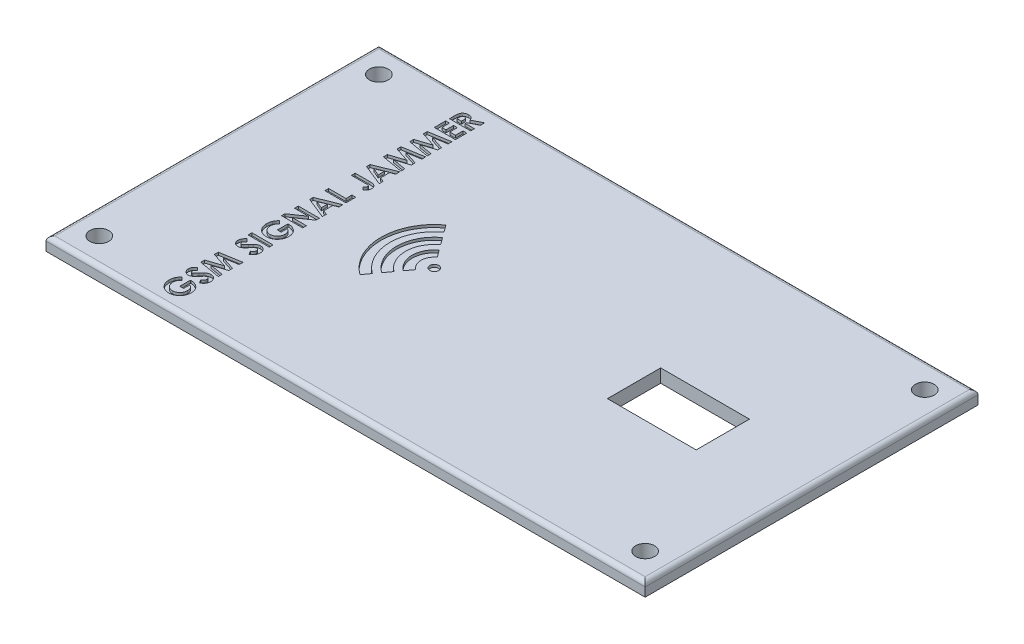
from build123d import *

# Parameters (mm, degrees)
SKETCH1_W                 = 135
SKETCH1_H                 = 75
BOSS_EXTRUDE1_DEPTH       = 3
SKETCH2_W                 = 20
SKETCH2_H                 = 12
CUT_EXTRUDE1_DEPTH        = 3
SKETCH7_W                 = 4.7625
SKETCH7_H                 = 0.854807692
CUT_EXTRUDE2_DEPTH        = 0.6
SKETCH8_R                 = 1
CUT_EXTRUDE3_DEPTH        = 0.6
F_4_0MM_DOWEL_HOLE1_D     = 4.25
F_4_0MM_DOWEL_HOLE1_DEPTH = 7.523171185
F_4_0MM_DOWEL_HOLE1_TIP   = 1.276828815
FILLET1_R                 = 1


with BuildPart() as part:
    # Sketch1 → Boss-Extrude1 (new body)
    with BuildSketch(Plane(origin=(0, 0, 0), x_dir=(1, 0, 0), z_dir=(0, 1, 0))):
        with Locations((67.5, 37.5)):
            Rectangle(SKETCH1_W, SKETCH1_H)
    extrude(amount=BOSS_EXTRUDE1_DEPTH)

    # Sketch2 → Cut-Extrude1 (cut)
    with BuildSketch(Plane(origin=(0, 3, 0), x_dir=(1, 0, 0), z_dir=(0, 1, 0))):
        with Locations((105, 37.5)):
            Rectangle(SKETCH2_W, SKETCH2_H)
    extrude(amount=-CUT_EXTRUDE1_DEPTH, mode=Mode.SUBTRACT)

    # Sketch7 → Cut-Extrude2 (cut)
    with BuildSketch(Plane(origin=(0, 3, 0), x_dir=(1, 0, 0), z_dir=(0, 1, 0))):
        with BuildLine():
            Line((23.338160871, 7.306017127), (23.957324032, 6.6591872))
            add(Edge.make_bspline(
                [(23.957324032, 6.6591872), (23.906052018, 6.607976545), (23.805447863, 6.507492788), (23.674504641, 6.343164172), (23.563177017, 6.172969598), (23.471635656, 5.996348887), (23.400628218, 5.813056007), (23.349834326, 5.623452671), (23.319707608, 5.427230421), (23.31548997, 5.294396716), (23.313356183, 5.22719351)],
                knots=[0, 0, 0, 0, 0.000217258, 0.000426297, 0.000628991, 0.000826548, 0.001021965, 0.001217513, 0.001414369, 0.001615942, 0.001615942, 0.001615942, 0.001615942], degree=3))
            add(Edge.make_bspline(
                [(23.313356183, 5.22719351), (23.314851318, 5.168930384), (23.317787146, 5.05452563), (23.340081624, 4.886418864), (23.377323542, 4.725782545), (23.428916015, 4.571857793), (23.496054083, 4.42558425), (23.577701753, 4.286114836), (23.674482851, 4.154306123), (23.784565735, 4.031202576), (23.904745004, 3.919097413), (24.033411846, 3.821291896), (24.168264114, 3.737584934), (24.310056355, 3.669746178), (24.457744893, 3.616832651), (24.611929925, 3.579833942), (24.772280944, 3.556119852), (24.88169152, 3.553334094), (24.937109188, 3.551923077)],
                knots=[0, 0, 0, 0, 0.000174754, 0.000343144, 0.000507682, 0.000668786, 0.000829303, 0.000989654, 0.001152803, 0.001319023, 0.001484411, 0.001645073, 0.001803137, 0.00195974, 0.002115749, 0.002272862, 0.002434766, 0.002600942, 0.002600942, 0.002600942, 0.002600942], degree=3))
            add(Edge.make_bspline(
                [(24.937109188, 3.551923077), (24.994443404, 3.553242806), (25.107399658, 3.555842852), (25.27316782, 3.580819237), (25.432648723, 3.619299664), (25.584659126, 3.675624723), (25.731281088, 3.744943908), (25.86967543, 3.83285169), (26.001951618, 3.935362339), (26.125821864, 4.052286207), (26.239955534, 4.179488914), (26.338572241, 4.317181415), (26.4231283, 4.461616339), (26.4922104, 4.613704993), (26.544395753, 4.773251712), (26.582972772, 4.93948426), (26.60620628, 5.113324289), (26.609035652, 5.231893196), (26.610471568, 5.292067308)],
                knots=[0, 0, 0, 0, 0.000171894, 0.000338655, 0.000501783, 0.00066325, 0.000824119, 0.000987439, 0.001154033, 0.001325466, 0.001497786, 0.001665917, 0.001832653, 0.001999171, 0.002166006, 0.002335407, 0.002510543, 0.002691015, 0.002691015, 0.002691015, 0.002691015], degree=3))
            add(Edge.make_bspline(
                [(26.610471568, 5.292067308), (26.610118385, 5.331210592), (26.609425008, 5.408057568), (26.59816955, 5.520778986), (26.582078564, 5.62873903), (26.560776009, 5.732355799), (26.530629072, 5.830583043), (26.495375941, 5.924780783), (26.453770217, 6.014397106), (26.404376426, 6.09894612), (26.349012023, 6.179686159), (26.285663373, 6.255861482), (26.215758755, 6.328808294), (26.138444185, 6.397674219), (26.053028378, 6.461293683), (25.961080966, 6.521704891), (25.861689424, 6.578216145), (25.791504153, 6.611607155), (25.755663876, 6.628658353)],
                knots=[0, 0, 0, 0, 0.00011738, 0.000230443, 0.000339461, 0.000444807, 0.000547426, 0.000647362, 0.000746379, 0.000843413, 0.000940799, 0.001039742, 0.001140277, 0.001243669, 0.001349948, 0.001459495, 0.001573568, 0.001692607, 0.001692607, 0.001692607, 0.001692607], degree=3))
            Line((25.755663876, 6.628658353), (25.755663876, 5.261538462))
            Line((25.755663876, 5.261538462), (24.900856183, 5.261538462))
            Line((24.900856183, 5.261538462), (24.900856183, 7.636110276))
            Line((24.900856183, 7.636110276), (25.104063816, 7.642788462))
            add(Edge.make_bspline(
                [(25.104063816, 7.642788462), (25.156252691, 7.641930364), (25.260537308, 7.640215702), (25.415799336, 7.624545482), (25.569002134, 7.598588), (25.719991837, 7.563101645), (25.869509069, 7.518628237), (26.01612221, 7.46191083), (26.160825039, 7.395494684), (26.303004592, 7.321081645), (26.439424151, 7.237457056), (26.568615708, 7.147443582), (26.690260901, 7.052230521), (26.802845911, 6.950239119), (26.906246602, 6.841691569), (27.001765919, 6.727898728), (27.090237668, 6.608821027), (27.168230316, 6.482349265), (27.237766338, 6.350609057), (27.299587689, 6.213607668), (27.350656037, 6.070543125), (27.392864253, 5.922056781), (27.425331935, 5.768078632), (27.44762025, 5.608671435), (27.462758501, 5.443729396), (27.464428849, 5.331853392), (27.46527926, 5.274894832)],
                knots=[0, 0, 0, 0, 0.000156533, 0.000312787, 0.000467589, 0.000622403, 0.000777839, 0.000935173, 0.001093558, 0.001255296, 0.001416298, 0.001573237, 0.001727451, 0.001879416, 0.002028541, 0.002176833, 0.002324904, 0.002473156, 0.002622097, 0.002771563, 0.002923658, 0.003077374, 0.00323436, 0.00339532, 0.003560035, 0.003730872, 0.003730872, 0.003730872, 0.003730872], degree=3))
            add(Edge.make_bspline(
                [(27.46527926, 5.274894832), (27.464429267, 5.214126151), (27.462744328, 5.0936645), (27.447305867, 4.915505531), (27.421036225, 4.742734744), (27.387428249, 4.57443496), (27.341155728, 4.411829583), (27.286016798, 4.25352959), (27.219709968, 4.100820035), (27.144785923, 3.952945679), (27.059764356, 3.811854234), (26.966194498, 3.677846513), (26.863458926, 3.55165804), (26.75328156, 3.431995149), (26.632953107, 3.321653993), (26.506374372, 3.216522214), (26.368902553, 3.12169422), (26.224995749, 3.033088366), (26.074709712, 2.954382683), (25.920840856, 2.885507557), (25.764504008, 2.827046132), (25.604633786, 2.780215561), (25.442172146, 2.743117084), (25.27653831, 2.716036747), (25.108164136, 2.700886712), (24.995015237, 2.698378075), (24.938063215, 2.697115385)],
                knots=[0, 0, 0, 0, 0.000182281, 0.000361336, 0.000535926, 0.000706376, 0.00087582, 0.001042677, 0.00120891, 0.001374883, 0.001539643, 0.001702678, 0.001864787, 0.002027478, 0.00219017, 0.002354224, 0.002520698, 0.002690699, 0.002860968, 0.003029226, 0.003196159, 0.003361283, 0.003528611, 0.003695805, 0.003864406, 0.004035273, 0.004035273, 0.004035273, 0.004035273], degree=3))
            add(Edge.make_bspline(
                [(24.938063215, 2.697115385), (24.860366388, 2.69879944), (24.706938191, 2.702124951), (24.480959382, 2.733041791), (24.262557879, 2.780899005), (24.052338117, 2.850605168), (23.849452604, 2.938481046), (23.654079862, 3.045715015), (23.466470761, 3.173195929), (23.350330396, 3.271920658), (23.291413575, 3.322002704)],
                knots=[0, 0, 0, 0, 0.000232978, 0.000460062, 0.000682956, 0.000902889, 0.001123366, 0.00134539, 0.001570577, 0.001802427, 0.001802427, 0.001802427, 0.001802427], degree=3))
            add(Edge.make_bspline(
                [(23.291413575, 3.322002704), (23.257327573, 3.353095991), (23.18966737, 3.414815699), (23.095652142, 3.513474538), (23.007274349, 3.614635394), (22.926407988, 3.719699359), (22.851282854, 3.828114132), (22.783307229, 3.94019175), (22.720316731, 4.055344279), (22.665527896, 4.174469771), (22.616405135, 4.296944585), (22.574840372, 4.423311145), (22.538023871, 4.55262299), (22.510015956, 4.686025181), (22.486693103, 4.822170039), (22.471060905, 4.962023963), (22.459603616, 5.105205845), (22.458902982, 5.202046869), (22.458548491, 5.251044171)],
                knots=[0, 0, 0, 0, 0.000138373, 0.000274669, 0.000408573, 0.000541196, 0.00067219, 0.000804067, 0.000934266, 0.001065731, 0.001197183, 0.001329926, 0.001464644, 0.001600307, 0.001738641, 0.001878869, 0.002022358, 0.002169306, 0.002169306, 0.002169306, 0.002169306], degree=3))
            add(Edge.make_bspline(
                [(22.458548491, 5.251044171), (22.459338362, 5.302262259), (22.460909915, 5.404167448), (22.471784038, 5.555683588), (22.488560247, 5.705094309), (22.513725519, 5.851769981), (22.544759536, 5.996202848), (22.584521794, 6.13764529), (22.629698881, 6.277020044), (22.665717392, 6.367752481), (22.683698731, 6.413048377)],
                knots=[0, 0, 0, 0, 0.000153646, 0.000305698, 0.000455514, 0.000604513, 0.000751971, 0.000898485, 0.001045107, 0.001191276, 0.001191276, 0.001191276, 0.001191276], degree=3))
            add(Edge.make_bspline(
                [(22.683698731, 6.413048377), (22.70031116, 6.451163232), (22.73410038, 6.528687793), (22.796027849, 6.641402269), (22.864331272, 6.754857355), (22.943478699, 6.865977411), (23.028978292, 6.97798003), (23.123797442, 7.088579856), (23.227063517, 7.198606764), (23.300648823, 7.269749993), (23.338160871, 7.306017127)],
                knots=[0, 0, 0, 0, 0.000124671, 0.000253578, 0.000385454, 0.00052176, 0.000662585, 0.000808076, 0.000958586, 0.001115099, 0.001115099, 0.001115099, 0.001115099], degree=3))
        make_face()
        with BuildLine():
            Line((23.216999513, 10.939903846), (23.801817722, 10.30070613))
            add(Edge.make_bspline(
                [(23.801817722, 10.30070613), (23.763194695, 10.27332564), (23.68904387, 10.220758919), (23.589754167, 10.135553747), (23.505052662, 10.05073332), (23.435293198, 9.965511828), (23.380899615, 9.879133901), (23.342388357, 9.791749477), (23.317906386, 9.703853965), (23.314857791, 9.644801748), (23.313356183, 9.615715144)],
                knots=[0, 0, 0, 0, 0.000141967, 0.000272557, 0.000391963, 0.000501178, 0.000602304, 0.000697138, 0.000786923, 0.000874074, 0.000874074, 0.000874074, 0.000874074], degree=3))
            add(Edge.make_bspline(
                [(23.313356183, 9.615715144), (23.31427938, 9.588570603), (23.316061832, 9.536161626), (23.334670829, 9.461796748), (23.364741967, 9.394967342), (23.406280446, 9.337453562), (23.455889443, 9.291184978), (23.508700643, 9.25520839), (23.566282239, 9.234302325), (23.605772706, 9.231617573), (23.62532283, 9.230288462)],
                knots=[0, 0, 0, 0, 8.1294e-05, 0.000156957, 0.000228255, 0.00030001, 0.000368174, 0.000430887, 0.000490633, 0.000549211, 0.000549211, 0.000549211, 0.000549211], degree=3))
            add(Edge.make_bspline(
                [(23.62532283, 9.230288462), (23.645145699, 9.231129787), (23.685066202, 9.2328241), (23.74357467, 9.249188858), (23.800744255, 9.273855222), (23.835546102, 9.297424939), (23.85333515, 9.309472656)],
                knots=[0, 0, 0, 0, 5.9342e-05, 0.000119506, 0.000181017, 0.000245334, 0.000245334, 0.000245334, 0.000245334], degree=3))
            add(Edge.make_bspline(
                [(23.85333515, 9.309472656), (23.867122926, 9.320467893), (23.89904395, 9.345923719), (23.950363845, 9.393032283), (24.011022778, 9.454544825), (24.082281109, 9.528932692), (24.164815393, 9.615936386), (24.257246962, 9.716904764), (24.358676844, 9.832575542), (24.430184397, 9.913706305), (24.467728179, 9.956302584)],
                knots=[0, 0, 0, 0, 5.2895e-05, 0.00012246, 0.000208809, 0.000312042, 0.000431494, 0.000568572, 0.00072267, 0.000893011, 0.000893011, 0.000893011, 0.000893011], degree=3))
            add(Edge.make_bspline(
                [(24.467728179, 9.956302584), (24.502389537, 9.996373186), (24.568169594, 10.072418864), (24.661687358, 10.180479634), (24.745445396, 10.276065375), (24.820070913, 10.358306775), (24.882490736, 10.429661399), (24.936545017, 10.486973399), (24.979869118, 10.532695607), (25.006066886, 10.558660463), (25.017247409, 10.569741587)],
                knots=[0, 0, 0, 0, 0.000158945, 0.000301644, 0.000428727, 0.000540201, 0.000634799, 0.000713099, 0.000776526, 0.000823748, 0.000823748, 0.000823748, 0.000823748], degree=3))
            add(Edge.make_bspline(
                [(25.017247409, 10.569741587), (25.062751775, 10.611782989), (25.150227146, 10.69260133), (25.285752142, 10.797701029), (25.41793544, 10.88382102), (25.548937238, 10.951221945), (25.681782233, 11.001657752), (25.819335425, 11.036992325), (25.962641215, 11.058476149), (26.060242025, 11.060829119), (26.109607686, 11.062019231)],
                knots=[0, 0, 0, 0, 0.00018579, 0.000357154, 0.000513815, 0.000658456, 0.000798256, 0.000939175, 0.00108381, 0.001231835, 0.001231835, 0.001231835, 0.001231835], degree=3))
            add(Edge.make_bspline(
                [(26.109607686, 11.062019231), (26.157706788, 11.061166736), (26.252079015, 11.05949411), (26.390178718, 11.039007649), (26.522346111, 11.009795152), (26.6471431, 10.964627532), (26.766617918, 10.909577414), (26.878910538, 10.840564482), (26.985153575, 10.759516985), (27.0834624, 10.66662896), (27.172627935, 10.563865634), (27.252163403, 10.453708893), (27.317308332, 10.334659634), (27.373099405, 10.209088939), (27.412801366, 10.074704237), (27.44403614, 9.933954769), (27.462335389, 9.785377597), (27.464283831, 9.683818543), (27.46527926, 9.631933594)],
                knots=[0, 0, 0, 0, 0.000144172, 0.00028287, 0.000418019, 0.000549578, 0.000680179, 0.000812055, 0.000944097, 0.001080426, 0.001217022, 0.00135177, 0.001487151, 0.001623446, 0.001763168, 0.001906694, 0.002055675, 0.002211287, 0.002211287, 0.002211287, 0.002211287], degree=3))
            add(Edge.make_bspline(
                [(27.46527926, 9.631933594), (27.464557188, 9.5912014), (27.46312707, 9.510528296), (27.451434805, 9.391632196), (27.432605778, 9.276809788), (27.405474835, 9.166259117), (27.371567037, 9.059115268), (27.32828056, 8.956422656), (27.27851856, 8.857443274), (27.2212118, 8.762380586), (27.154616795, 8.671834052), (27.081340512, 8.583266143), (26.997833093, 8.499594266), (26.905715834, 8.418943275), (26.804423775, 8.342353915), (26.695493953, 8.267211308), (26.5768687, 8.196885229), (26.493653585, 8.153440568), (26.451149152, 8.13125)],
                knots=[0, 0, 0, 0, 0.000122175, 0.000241977, 0.000358039, 0.000470957, 0.000583192, 0.000694813, 0.000804891, 0.000915331, 0.001027347, 0.001141803, 0.001259859, 0.001381557, 0.001508829, 0.001640609, 0.001778372, 0.001922206, 0.001922206, 0.001922206, 0.001922206], degree=3))
            Line((26.451149152, 8.13125), (25.999894645, 8.883022837))
            add(Edge.make_bspline(
                [(25.999894645, 8.883022837), (26.048142871, 8.91077979), (26.140638843, 8.963992241), (26.264918906, 9.054165714), (26.371344207, 9.146543834), (26.458033673, 9.2432623), (26.526146454, 9.343145051), (26.574824572, 9.446674545), (26.604956273, 9.55392352), (26.608636049, 9.626976649), (26.610471568, 9.663416466)],
                knots=[0, 0, 0, 0, 0.000166886, 0.000319936, 0.000459853, 0.000588914, 0.000708515, 0.000821191, 0.000930887, 0.001040064, 0.001040064, 0.001040064, 0.001040064], degree=3))
            add(Edge.make_bspline(
                [(26.610471568, 9.663416466), (26.608972584, 9.700480978), (26.606064336, 9.772391528), (26.579201731, 9.875034636), (26.53702547, 9.969141724), (26.476845762, 10.050487196), (26.407389232, 10.119365413), (26.330115667, 10.17020149), (26.246507534, 10.202137057), (26.188427826, 10.205513421), (26.159217061, 10.207211538)],
                knots=[0, 0, 0, 0, 0.000111, 0.000215355, 0.000316104, 0.00041858, 0.000517081, 0.000608109, 0.000694426, 0.000781765, 0.000781765, 0.000781765, 0.000781765], degree=3))
            add(Edge.make_bspline(
                [(26.159217061, 10.207211538), (26.132041197, 10.205643396), (26.076836032, 10.202457866), (25.994754828, 10.178994232), (25.912710953, 10.142313414), (25.845416347, 10.098917421), (25.789072398, 10.054756564), (25.740252915, 10.012528824), (25.686315932, 9.961106607), (25.627193602, 9.900620297), (25.562365456, 9.831869077), (25.491837841, 9.754795032), (25.416232022, 9.668515583), (25.364730085, 9.607533098), (25.337800294, 9.575646034)],
                knots=[0, 0, 0, 0, 8.1451e-05, 0.000165459, 0.000254286, 0.000350359, 0.000404747, 0.000469007, 0.000543915, 0.000628243, 0.000722725, 0.000827394, 0.000941643, 0.001066853, 0.001066853, 0.001066853, 0.001066853], degree=3))
            add(Edge.make_bspline(
                [(25.337800294, 9.575646034), (25.2865112, 9.515027404), (25.188071904, 9.398681907), (25.042679587, 9.234271766), (24.906799171, 9.08612067), (24.778742088, 8.955520571), (24.660901341, 8.840767547), (24.552230784, 8.742764055), (24.451965059, 8.662035311), (24.33241091, 8.578239429), (24.188021369, 8.497656808), (24.014414043, 8.427879792), (23.840653962, 8.383035228), (23.723840633, 8.377972571), (23.666345967, 8.375480769)],
                knots=[0, 0, 0, 0, 0.000238209, 0.000457195, 0.000658388, 0.000841215, 0.00100584, 0.001151778, 0.001280061, 0.001391748, 0.001589491, 0.001774445, 0.001952152, 0.002124396, 0.002124396, 0.002124396, 0.002124396], degree=3))
            add(Edge.make_bspline(
                [(23.666345967, 8.375480769), (23.625572015, 8.376513836), (23.54524295, 8.378549088), (23.427130449, 8.396703217), (23.313163036, 8.423836745), (23.203750723, 8.463236954), (23.09905215, 8.51439345), (22.998472707, 8.576446912), (22.903068248, 8.650850221), (22.811900316, 8.733631922), (22.729439616, 8.82593888), (22.65669726, 8.924168159), (22.594926384, 9.027888948), (22.545341079, 9.137500874), (22.505980152, 9.252108646), (22.478406245, 9.372001809), (22.461920046, 9.496955127), (22.459686344, 9.581955832), (22.458548491, 9.625255409)],
                knots=[0, 0, 0, 0, 0.000122249, 0.000240845, 0.000357696, 0.000473275, 0.000588906, 0.000706719, 0.000827127, 0.00095137, 0.00107568, 0.001197799, 0.001317566, 0.001437105, 0.001558086, 0.001680507, 0.001805586, 0.00193546, 0.00193546, 0.00193546, 0.00193546], degree=3))
            add(Edge.make_bspline(
                [(22.458548491, 9.625255409), (22.460601172, 9.681368429), (22.464690331, 9.793151533), (22.496667776, 9.958425285), (22.546951557, 10.119860964), (22.607626298, 10.24993866), (22.666372591, 10.353463193), (22.720546073, 10.432731833), (22.782368396, 10.513863389), (22.853581985, 10.595602044), (22.931851, 10.679931986), (23.018979603, 10.765607331), (23.114071473, 10.853540717), (23.18208912, 10.910611821), (23.216999513, 10.939903846)],
                knots=[0, 0, 0, 0, 0.000168236, 0.000335145, 0.000503208, 0.000674386, 0.000764555, 0.000860077, 0.000962162, 0.001070401, 0.001185154, 0.001307258, 0.001436894, 0.001573589, 0.001573589, 0.001573589, 0.001573589], degree=3))
        make_face()
        Polygon((22.580663876, 12.293667368), (22.580663876, 13.180911959), (25.902583948, 14.267548077), (22.580663876, 15.361816406), (22.580663876, 16.24047476), (27.343163876, 17.045673077), (27.343163876, 16.180371094), (24.335118503, 15.671875), (27.343163876, 14.681595553), (27.343163876, 13.847776442), (24.335118503, 12.863221154), (27.343163876, 12.355679087), (27.343163876, 11.489423077), align=None)
        with BuildLine():
            Line((23.216999513, 22.113461538), (23.801817722, 21.474263822))
            add(Edge.make_bspline(
                [(23.801817722, 21.474263822), (23.763194695, 21.446883333), (23.68904387, 21.394316612), (23.589754167, 21.309111439), (23.505052662, 21.224291012), (23.435293198, 21.13906952), (23.380899615, 21.052691593), (23.342388357, 20.96530717), (23.317906386, 20.877411657), (23.314857791, 20.81835944), (23.313356183, 20.789272837)],
                knots=[0, 0, 0, 0, 0.000141967, 0.000272557, 0.000391963, 0.000501178, 0.000602304, 0.000697138, 0.000786923, 0.000874074, 0.000874074, 0.000874074, 0.000874074], degree=3))
            add(Edge.make_bspline(
                [(23.313356183, 20.789272837), (23.31427938, 20.762128295), (23.316061832, 20.709719318), (23.334670829, 20.63535444), (23.364741967, 20.568525034), (23.406280446, 20.511011255), (23.455889443, 20.46474267), (23.508700643, 20.428766083), (23.566282239, 20.407860017), (23.605772706, 20.405175265), (23.62532283, 20.403846154)],
                knots=[0, 0, 0, 0, 8.1294e-05, 0.000156957, 0.000228255, 0.00030001, 0.000368174, 0.000430887, 0.000490633, 0.000549211, 0.000549211, 0.000549211, 0.000549211], degree=3))
            add(Edge.make_bspline(
                [(23.62532283, 20.403846154), (23.645145699, 20.40468748), (23.685066202, 20.406381793), (23.74357467, 20.422746551), (23.800744255, 20.447412914), (23.835546102, 20.470982631), (23.85333515, 20.483030349)],
                knots=[0, 0, 0, 0, 5.9342e-05, 0.000119506, 0.000181017, 0.000245334, 0.000245334, 0.000245334, 0.000245334], degree=3))
            add(Edge.make_bspline(
                [(23.85333515, 20.483030349), (23.867122926, 20.494025585), (23.89904395, 20.519481411), (23.950363845, 20.566589975), (24.011022778, 20.628102517), (24.082281109, 20.702490384), (24.164815393, 20.789494078), (24.257246962, 20.890462457), (24.358676844, 21.006133234), (24.430184397, 21.087263997), (24.467728179, 21.129860276)],
                knots=[0, 0, 0, 0, 5.2895e-05, 0.00012246, 0.000208809, 0.000312042, 0.000431494, 0.000568572, 0.00072267, 0.000893011, 0.000893011, 0.000893011, 0.000893011], degree=3))
            add(Edge.make_bspline(
                [(24.467728179, 21.129860276), (24.502389537, 21.169930879), (24.568169594, 21.245976557), (24.661687358, 21.354037326), (24.745445396, 21.449623067), (24.820070913, 21.531864467), (24.882490736, 21.603219091), (24.936545017, 21.660531091), (24.979869118, 21.706253299), (25.006066886, 21.732218156), (25.017247409, 21.743299279)],
                knots=[0, 0, 0, 0, 0.000158945, 0.000301644, 0.000428727, 0.000540201, 0.000634799, 0.000713099, 0.000776526, 0.000823748, 0.000823748, 0.000823748, 0.000823748], degree=3))
            add(Edge.make_bspline(
                [(25.017247409, 21.743299279), (25.062751775, 21.785340682), (25.150227146, 21.866159022), (25.285752142, 21.971258722), (25.41793544, 22.057378713), (25.548937238, 22.124779637), (25.681782233, 22.175215444), (25.819335425, 22.210550018), (25.962641215, 22.232033841), (26.060242025, 22.234386811), (26.109607686, 22.235576923)],
                knots=[0, 0, 0, 0, 0.00018579, 0.000357154, 0.000513815, 0.000658456, 0.000798256, 0.000939175, 0.00108381, 0.001231835, 0.001231835, 0.001231835, 0.001231835], degree=3))
            add(Edge.make_bspline(
                [(26.109607686, 22.235576923), (26.157706788, 22.234724428), (26.252079015, 22.233051802), (26.390178718, 22.212565341), (26.522346111, 22.183352844), (26.6471431, 22.138185224), (26.766617918, 22.083135106), (26.878910538, 22.014122174), (26.985153575, 21.933074677), (27.0834624, 21.840186652), (27.172627935, 21.737423326), (27.252163403, 21.627266585), (27.317308332, 21.508217326), (27.373099405, 21.382646631), (27.412801366, 21.248261929), (27.44403614, 21.107512461), (27.462335389, 20.958935289), (27.464283831, 20.857376235), (27.46527926, 20.805491286)],
                knots=[0, 0, 0, 0, 0.000144172, 0.00028287, 0.000418019, 0.000549578, 0.000680179, 0.000812055, 0.000944097, 0.001080426, 0.001217022, 0.00135177, 0.001487151, 0.001623446, 0.001763168, 0.001906694, 0.002055675, 0.002211287, 0.002211287, 0.002211287, 0.002211287], degree=3))
            add(Edge.make_bspline(
                [(27.46527926, 20.805491286), (27.464557188, 20.764759092), (27.46312707, 20.684085988), (27.451434805, 20.565189888), (27.432605778, 20.45036748), (27.405474835, 20.33981681), (27.371567037, 20.23267296), (27.32828056, 20.129980348), (27.27851856, 20.031000966), (27.2212118, 19.935938278), (27.154616795, 19.845391745), (27.081340512, 19.756823835), (26.997833093, 19.673151958), (26.905715834, 19.592500967), (26.804423775, 19.515911608), (26.695493953, 19.440769), (26.5768687, 19.370442921), (26.493653585, 19.32699826), (26.451149152, 19.304807692)],
                knots=[0, 0, 0, 0, 0.000122175, 0.000241977, 0.000358039, 0.000470957, 0.000583192, 0.000694813, 0.000804891, 0.000915331, 0.001027347, 0.001141803, 0.001259859, 0.001381557, 0.001508829, 0.001640609, 0.001778372, 0.001922206, 0.001922206, 0.001922206, 0.001922206], degree=3))
            Line((26.451149152, 19.304807692), (25.999894645, 20.056580529))
            add(Edge.make_bspline(
                [(25.999894645, 20.056580529), (26.048142871, 20.084337482), (26.140638843, 20.137549933), (26.264918906, 20.227723406), (26.371344207, 20.320101526), (26.458033673, 20.416819992), (26.526146454, 20.516702744), (26.574824572, 20.620232238), (26.604956273, 20.727481212), (26.608636049, 20.800534341), (26.610471568, 20.836974159)],
                knots=[0, 0, 0, 0, 0.000166886, 0.000319936, 0.000459853, 0.000588914, 0.000708515, 0.000821191, 0.000930887, 0.001040064, 0.001040064, 0.001040064, 0.001040064], degree=3))
            add(Edge.make_bspline(
                [(26.610471568, 20.836974159), (26.608972584, 20.87403867), (26.606064336, 20.94594922), (26.579201731, 21.048592328), (26.53702547, 21.142699416), (26.476845762, 21.224044888), (26.407389232, 21.292923105), (26.330115667, 21.343759183), (26.246507534, 21.37569475), (26.188427826, 21.379071113), (26.159217061, 21.380769231)],
                knots=[0, 0, 0, 0, 0.000111, 0.000215355, 0.000316104, 0.00041858, 0.000517081, 0.000608109, 0.000694426, 0.000781765, 0.000781765, 0.000781765, 0.000781765], degree=3))
            add(Edge.make_bspline(
                [(26.159217061, 21.380769231), (26.132041197, 21.379201089), (26.076836032, 21.376015559), (25.994754828, 21.352551924), (25.912710953, 21.315871107), (25.845416347, 21.272475113), (25.789072398, 21.228314256), (25.740252915, 21.186086516), (25.686315932, 21.134664299), (25.627193602, 21.074177989), (25.562365456, 21.005426769), (25.491837841, 20.928352724), (25.416232022, 20.842073275), (25.364730085, 20.78109079), (25.337800294, 20.749203726)],
                knots=[0, 0, 0, 0, 8.1451e-05, 0.000165459, 0.000254286, 0.000350359, 0.000404747, 0.000469007, 0.000543915, 0.000628243, 0.000722725, 0.000827394, 0.000941643, 0.001066853, 0.001066853, 0.001066853, 0.001066853], degree=3))
            add(Edge.make_bspline(
                [(25.337800294, 20.749203726), (25.2865112, 20.688585097), (25.188071904, 20.572239599), (25.042679587, 20.407829458), (24.906799171, 20.259678362), (24.778742088, 20.129078263), (24.660901341, 20.014325239), (24.552230784, 19.916321747), (24.451965059, 19.835593004), (24.33241091, 19.751797122), (24.188021369, 19.6712145), (24.014414043, 19.601437485), (23.840653962, 19.55659292), (23.723840633, 19.551530264), (23.666345967, 19.549038462)],
                knots=[0, 0, 0, 0, 0.000238209, 0.000457195, 0.000658388, 0.000841215, 0.00100584, 0.001151778, 0.001280061, 0.001391748, 0.001589491, 0.001774445, 0.001952152, 0.002124396, 0.002124396, 0.002124396, 0.002124396], degree=3))
            add(Edge.make_bspline(
                [(23.666345967, 19.549038462), (23.625572015, 19.550071528), (23.54524295, 19.552106781), (23.427130449, 19.570260909), (23.313163036, 19.597394437), (23.203750723, 19.636794646), (23.09905215, 19.687951142), (22.998472707, 19.750004604), (22.903068248, 19.824407913), (22.811900316, 19.907189615), (22.729439616, 19.999496572), (22.65669726, 20.097725851), (22.594926384, 20.20144664), (22.545341079, 20.311058567), (22.505980152, 20.425666339), (22.478406245, 20.545559501), (22.461920046, 20.67051282), (22.459686344, 20.755513525), (22.458548491, 20.798813101)],
                knots=[0, 0, 0, 0, 0.000122249, 0.000240845, 0.000357696, 0.000473275, 0.000588906, 0.000706719, 0.000827127, 0.00095137, 0.00107568, 0.001197799, 0.001317566, 0.001437105, 0.001558086, 0.001680507, 0.001805586, 0.00193546, 0.00193546, 0.00193546, 0.00193546], degree=3))
            add(Edge.make_bspline(
                [(22.458548491, 20.798813101), (22.460601172, 20.854926121), (22.464690331, 20.966709226), (22.496667776, 21.131982977), (22.546951557, 21.293418656), (22.607626298, 21.423496352), (22.666372591, 21.527020885), (22.720546073, 21.606289526), (22.782368396, 21.687421081), (22.853581985, 21.769159736), (22.931851, 21.853489678), (23.018979603, 21.939165023), (23.114071473, 22.027098409), (23.18208912, 22.084169513), (23.216999513, 22.113461538)],
                knots=[0, 0, 0, 0, 0.000168236, 0.000335145, 0.000503208, 0.000674386, 0.000764555, 0.000860077, 0.000962162, 0.001070401, 0.001185154, 0.001307258, 0.001436894, 0.001573589, 0.001573589, 0.001573589, 0.001573589], degree=3))
        make_face()
        with Locations((24.961913876, 23.395673077)):
            Rectangle(SKETCH7_W, SKETCH7_H)
        with BuildLine():
            Line((23.338160871, 29.286786358), (23.957324032, 28.63995643))
            add(Edge.make_bspline(
                [(23.957324032, 28.63995643), (23.906052018, 28.588745776), (23.805447863, 28.488262018), (23.674504641, 28.323933402), (23.563177017, 28.153738829), (23.471635656, 27.977118118), (23.400628218, 27.793825238), (23.349834326, 27.604221902), (23.319707608, 27.407999652), (23.31548997, 27.275165947), (23.313356183, 27.20796274)],
                knots=[0, 0, 0, 0, 0.000217258, 0.000426297, 0.000628991, 0.000826548, 0.001021965, 0.001217513, 0.001414369, 0.001615942, 0.001615942, 0.001615942, 0.001615942], degree=3))
            add(Edge.make_bspline(
                [(23.313356183, 27.20796274), (23.314851318, 27.149699615), (23.317787146, 27.035294861), (23.340081624, 26.867188095), (23.377323542, 26.706551775), (23.428916015, 26.552627023), (23.496054083, 26.406353481), (23.577701753, 26.266884067), (23.674482851, 26.135075354), (23.784565735, 26.011971806), (23.904745004, 25.899866644), (24.033411846, 25.802061127), (24.168264114, 25.718354165), (24.310056355, 25.650515409), (24.457744893, 25.597601882), (24.611929925, 25.560603172), (24.772280944, 25.536889083), (24.88169152, 25.534103325), (24.937109188, 25.532692308)],
                knots=[0, 0, 0, 0, 0.000174754, 0.000343144, 0.000507682, 0.000668786, 0.000829303, 0.000989654, 0.001152803, 0.001319023, 0.001484411, 0.001645073, 0.001803137, 0.00195974, 0.002115749, 0.002272862, 0.002434766, 0.002600942, 0.002600942, 0.002600942, 0.002600942], degree=3))
            add(Edge.make_bspline(
                [(24.937109188, 25.532692308), (24.994443404, 25.534012037), (25.107399658, 25.536612083), (25.27316782, 25.561588468), (25.432648723, 25.600068895), (25.584659126, 25.656393954), (25.731281088, 25.725713139), (25.86967543, 25.81362092), (26.001951618, 25.91613157), (26.125821864, 26.033055438), (26.239955534, 26.160258145), (26.338572241, 26.297950646), (26.4231283, 26.44238557), (26.4922104, 26.594474224), (26.544395753, 26.754020942), (26.582972772, 26.920253491), (26.60620628, 27.09409352), (26.609035652, 27.212662426), (26.610471568, 27.272836538)],
                knots=[0, 0, 0, 0, 0.000171894, 0.000338655, 0.000501783, 0.00066325, 0.000824119, 0.000987439, 0.001154033, 0.001325466, 0.001497786, 0.001665917, 0.001832653, 0.001999171, 0.002166006, 0.002335407, 0.002510543, 0.002691015, 0.002691015, 0.002691015, 0.002691015], degree=3))
            add(Edge.make_bspline(
                [(26.610471568, 27.272836538), (26.610118385, 27.311979822), (26.609425008, 27.388826798), (26.59816955, 27.501548217), (26.582078564, 27.609508261), (26.560776009, 27.71312503), (26.530629072, 27.811352273), (26.495375941, 27.905550014), (26.453770217, 27.995166337), (26.404376426, 28.07971535), (26.349012023, 28.16045539), (26.285663373, 28.236630713), (26.215758755, 28.309577524), (26.138444185, 28.37844345), (26.053028378, 28.442062913), (25.961080966, 28.502474121), (25.861689424, 28.558985376), (25.791504153, 28.592376385), (25.755663876, 28.609427584)],
                knots=[0, 0, 0, 0, 0.00011738, 0.000230443, 0.000339461, 0.000444807, 0.000547426, 0.000647362, 0.000746379, 0.000843413, 0.000940799, 0.001039742, 0.001140277, 0.001243669, 0.001349948, 0.001459495, 0.001573568, 0.001692607, 0.001692607, 0.001692607, 0.001692607], degree=3))
            Line((25.755663876, 28.609427584), (25.755663876, 27.242307692))
            Line((25.755663876, 27.242307692), (24.900856183, 27.242307692))
            Line((24.900856183, 27.242307692), (24.900856183, 29.616879507))
            Line((24.900856183, 29.616879507), (25.104063816, 29.623557692))
            add(Edge.make_bspline(
                [(25.104063816, 29.623557692), (25.156252691, 29.622699595), (25.260537308, 29.620984932), (25.415799336, 29.605314713), (25.569002134, 29.579357231), (25.719991837, 29.543870876), (25.869509069, 29.499397468), (26.01612221, 29.442680061), (26.160825039, 29.376263915), (26.303004592, 29.301850876), (26.439424151, 29.218226287), (26.568615708, 29.128212813), (26.690260901, 29.032999752), (26.802845911, 28.93100835), (26.906246602, 28.8224608), (27.001765919, 28.708667959), (27.090237668, 28.589590258), (27.168230316, 28.463118496), (27.237766338, 28.331378288), (27.299587689, 28.194376898), (27.350656037, 28.051312356), (27.392864253, 27.902826012), (27.425331935, 27.748847863), (27.44762025, 27.589440666), (27.462758501, 27.424498626), (27.464428849, 27.312622623), (27.46527926, 27.255664062)],
                knots=[0, 0, 0, 0, 0.000156533, 0.000312787, 0.000467589, 0.000622403, 0.000777839, 0.000935173, 0.001093558, 0.001255296, 0.001416298, 0.001573237, 0.001727451, 0.001879416, 0.002028541, 0.002176833, 0.002324904, 0.002473156, 0.002622097, 0.002771563, 0.002923658, 0.003077374, 0.00323436, 0.00339532, 0.003560035, 0.003730872, 0.003730872, 0.003730872, 0.003730872], degree=3))
            add(Edge.make_bspline(
                [(27.46527926, 27.255664062), (27.464429267, 27.194895381), (27.462744328, 27.07443373), (27.447305867, 26.896274762), (27.421036225, 26.723503974), (27.387428249, 26.555204191), (27.341155728, 26.392598814), (27.286016798, 26.23429882), (27.219709968, 26.081589266), (27.144785923, 25.93371491), (27.059764356, 25.792623464), (26.966194498, 25.658615744), (26.863458926, 25.53242727), (26.75328156, 25.41276438), (26.632953107, 25.302423224), (26.506374372, 25.197291444), (26.368902553, 25.102463451), (26.224995749, 25.013857597), (26.074709712, 24.935151914), (25.920840856, 24.866276788), (25.764504008, 24.807815363), (25.604633786, 24.760984792), (25.442172146, 24.723886315), (25.27653831, 24.696805978), (25.108164136, 24.681655943), (24.995015237, 24.679147305), (24.938063215, 24.677884615)],
                knots=[0, 0, 0, 0, 0.000182281, 0.000361336, 0.000535926, 0.000706376, 0.00087582, 0.001042677, 0.00120891, 0.001374883, 0.001539643, 0.001702678, 0.001864787, 0.002027478, 0.00219017, 0.002354224, 0.002520698, 0.002690699, 0.002860968, 0.003029226, 0.003196159, 0.003361283, 0.003528611, 0.003695805, 0.003864406, 0.004035273, 0.004035273, 0.004035273, 0.004035273], degree=3))
            add(Edge.make_bspline(
                [(24.938063215, 24.677884615), (24.860366388, 24.679568671), (24.706938191, 24.682894181), (24.480959382, 24.713811022), (24.262557879, 24.761668236), (24.052338117, 24.831374399), (23.849452604, 24.919250276), (23.654079862, 25.026484246), (23.466470761, 25.15396516), (23.350330396, 25.252689889), (23.291413575, 25.302771935)],
                knots=[0, 0, 0, 0, 0.000232978, 0.000460062, 0.000682956, 0.000902889, 0.001123366, 0.00134539, 0.001570577, 0.001802427, 0.001802427, 0.001802427, 0.001802427], degree=3))
            add(Edge.make_bspline(
                [(23.291413575, 25.302771935), (23.257327573, 25.333865222), (23.18966737, 25.395584929), (23.095652142, 25.494243769), (23.007274349, 25.595404624), (22.926407988, 25.70046859), (22.851282854, 25.808883363), (22.783307229, 25.920960981), (22.720316731, 26.03611351), (22.665527896, 26.155239001), (22.616405135, 26.277713816), (22.574840372, 26.404080376), (22.538023871, 26.533392221), (22.510015956, 26.666794412), (22.486693103, 26.802939269), (22.471060905, 26.942793194), (22.459603616, 27.085975076), (22.458902982, 27.1828161), (22.458548491, 27.231813401)],
                knots=[0, 0, 0, 0, 0.000138373, 0.000274669, 0.000408573, 0.000541196, 0.00067219, 0.000804067, 0.000934266, 0.001065731, 0.001197183, 0.001329926, 0.001464644, 0.001600307, 0.001738641, 0.001878869, 0.002022358, 0.002169306, 0.002169306, 0.002169306, 0.002169306], degree=3))
            add(Edge.make_bspline(
                [(22.458548491, 27.231813401), (22.459338362, 27.28303149), (22.460909915, 27.384936678), (22.471784038, 27.536452818), (22.488560247, 27.68586354), (22.513725519, 27.832539212), (22.544759536, 27.976972078), (22.584521794, 28.11841452), (22.629698881, 28.257789274), (22.665717392, 28.348521712), (22.683698731, 28.393817608)],
                knots=[0, 0, 0, 0, 0.000153646, 0.000305698, 0.000455514, 0.000604513, 0.000751971, 0.000898485, 0.001045107, 0.001191276, 0.001191276, 0.001191276, 0.001191276], degree=3))
            add(Edge.make_bspline(
                [(22.683698731, 28.393817608), (22.70031116, 28.431932463), (22.73410038, 28.509457024), (22.796027849, 28.6221715), (22.864331272, 28.735626586), (22.943478699, 28.846746642), (23.028978292, 28.958749261), (23.123797442, 29.069349086), (23.227063517, 29.179375994), (23.300648823, 29.250519223), (23.338160871, 29.286786358)],
                knots=[0, 0, 0, 0, 0.000124671, 0.000253578, 0.000385454, 0.00052176, 0.000662585, 0.000808076, 0.000958586, 0.001115099, 0.001115099, 0.001115099, 0.001115099], degree=3))
        make_face()
        Polygon((22.580663876, 30.478365385), (22.580663876, 31.248264724), (25.714640739, 33.409134615), (22.580663876, 33.409134615), (22.580663876, 34.263942308), (27.343163876, 34.263942308), (27.343163876, 33.48831881), (24.218727277, 31.333173077), (27.343163876, 31.333173077), (27.343163876, 30.478365385), align=None)
        Polygon((22.580663876, 36.829319411), (22.580663876, 37.622115385), (27.343163876, 39.545432692), (27.343163876, 38.632429387), (26.366240799, 38.262267127), (26.366240799, 36.187259615), (27.343163876, 35.817097356), (27.343163876, 34.905048077), align=None)
        Polygon((23.858105282, 37.225240385), (25.511433106, 36.511628606), (25.511433106, 37.938852163), align=None, mode=Mode.SUBTRACT)
        Polygon((22.580663876, 40.247596154), (22.580663876, 41.102403846), (26.488356183, 41.102403846), (26.488356183, 42.445673077), (27.343163876, 42.445673077), (27.343163876, 40.247596154), align=None)
        with BuildLine():
            Line((22.580663876, 46.23125), (22.580663876, 47.086057692))
            Line((22.580663876, 47.086057692), (25.742307505, 47.086057692))
            add(Edge.make_bspline(
                [(25.742307505, 47.086057692), (25.802735065, 47.085744294), (25.919167043, 47.085140438), (26.086786108, 47.079094763), (26.240467786, 47.070919953), (26.37996578, 47.059147407), (26.505273504, 47.041662053), (26.616703083, 47.021873649), (26.714710146, 47.000042452), (26.824390627, 46.963160387), (26.945877738, 46.905924173), (27.076977057, 46.819454183), (27.191184466, 46.712263763), (27.288814047, 46.587392267), (27.368719479, 46.447071323), (27.425027612, 46.291292838), (27.458995349, 46.122368015), (27.463143594, 46.005308529), (27.46527926, 45.945042067)],
                knots=[0, 0, 0, 0, 0.000181275, 0.000349281, 0.000503119, 0.000642958, 0.00076911, 0.000882515, 0.000982483, 0.001069973, 0.001229161, 0.001383952, 0.001539203, 0.001696846, 0.001857898, 0.002021485, 0.002191746, 0.00237242, 0.00237242, 0.00237242, 0.00237242], degree=3))
            add(Edge.make_bspline(
                [(27.46527926, 45.945042067), (27.46333545, 45.882255152), (27.459501496, 45.758414837), (27.426846056, 45.576790261), (27.374489561, 45.40222634), (27.298788352, 45.235626175), (27.203962359, 45.074707292), (27.086339946, 44.922390224), (26.949569098, 44.775494797), (26.844614582, 44.688414292), (26.790782566, 44.64375)],
                knots=[0, 0, 0, 0, 0.000188236, 0.000371275, 0.00055175, 0.000733666, 0.00091888, 0.001110836, 0.001309936, 0.001519587, 0.001519587, 0.001519587, 0.001519587], degree=3))
            Line((26.790782566, 44.64375), (26.192607986, 45.290579928))
            add(Edge.make_bspline(
                [(26.192607986, 45.290579928), (26.230902321, 45.324447213), (26.302561317, 45.387822008), (26.396006408, 45.483325956), (26.471078752, 45.569475663), (26.52522911, 45.65068632), (26.563399068, 45.72732287), (26.590893961, 45.8010342), (26.606457632, 45.874118), (26.609153842, 45.922399386), (26.610471568, 45.945996094)],
                knots=[0, 0, 0, 0, 0.000153314, 0.000286891, 0.000400616, 0.000495608, 0.000578805, 0.000656971, 0.000731067, 0.000801896, 0.000801896, 0.000801896, 0.000801896], degree=3))
            add(Edge.make_bspline(
                [(26.610471568, 45.945996094), (26.609160527, 45.968778563), (26.606646665, 46.012462926), (26.582835895, 46.073690373), (26.541387155, 46.123665652), (26.495683867, 46.157615987), (26.448893471, 46.178687482), (26.403668579, 46.192591148), (26.349091895, 46.204714852), (26.285414, 46.215103962), (26.212467952, 46.222656219), (26.13030082, 46.226612186), (26.038738127, 46.231159954), (25.974461261, 46.231219018), (25.940745005, 46.23125)],
                knots=[0, 0, 0, 0, 6.8165e-05, 0.000130702, 0.000193131, 0.000260678, 0.000299525, 0.000346593, 0.000402368, 0.000467144, 0.000540051, 0.000622235, 0.000713901, 0.000815033, 0.000815033, 0.000815033, 0.000815033], degree=3))
            Line((25.940745005, 46.23125), (22.580663876, 46.23125))
        make_face()
        Polygon((22.580663876, 49.651434796), (22.580663876, 50.444230769), (27.343163876, 52.367548077), (27.343163876, 51.454544772), (26.366240799, 51.084382512), (26.366240799, 49.009375), (27.343163876, 48.63921274), (27.343163876, 47.727163462), align=None)
        Polygon((23.858105282, 50.047355769), (25.511433106, 49.33374399), (25.511433106, 50.760967548), align=None, mode=Mode.SUBTRACT)
        Polygon((22.580663876, 53.446551983), (22.580663876, 54.333796575), (25.902583948, 55.420432692), (22.580663876, 56.514701022), (22.580663876, 57.393359375), (27.343163876, 58.198557692), (27.343163876, 57.333255709), (24.335118503, 56.824759615), (27.343163876, 55.834480168), (27.343163876, 55.000661058), (24.335118503, 54.016105769), (27.343163876, 53.508563702), (27.343163876, 52.642307692), align=None)
        Polygon((22.580663876, 59.369148137), (22.580663876, 60.256392728), (25.902583948, 61.343028846), (22.580663876, 62.437297175), (22.580663876, 63.315955529), (27.343163876, 64.121153846), (27.343163876, 63.255851863), (24.335118503, 62.747355769), (27.343163876, 61.757076322), (27.343163876, 60.923257212), (24.335118503, 59.938701923), (27.343163876, 59.431159856), (27.343163876, 58.564903846), align=None)
        Polygon((22.580663876, 64.914903846), (22.580663876, 67.479326923), (23.435471568, 67.479326923), (23.435471568, 65.769711538), (24.351336953, 65.769711538), (24.351336953, 67.479326923), (25.206144645, 67.479326923), (25.206144645, 65.769711538), (26.488356183, 65.769711538), (26.488356183, 67.479326923), (27.343163876, 67.479326923), (27.343163876, 64.914903846), align=None)
        with BuildLine():
            Line((22.580663876, 68.334134615), (22.580663876, 69.330138221))
            add(Edge.make_bspline(
                [(22.580663876, 69.330138221), (22.58089411, 69.395974244), (22.581336914, 69.52259546), (22.588473313, 69.705168535), (22.598187654, 69.872914601), (22.613741065, 70.025917178), (22.632077416, 70.164547901), (22.655979136, 70.28836247), (22.68271637, 70.397750853), (22.716167242, 70.49350211), (22.75383954, 70.579941425), (22.797253405, 70.660422676), (22.845472547, 70.737322223), (22.901618727, 70.808161875), (22.960682275, 70.877083215), (23.02664651, 70.940693306), (23.098365582, 71.000085054), (23.175825165, 71.05418626), (23.257388201, 71.103937232), (23.343349694, 71.146733061), (23.433010414, 71.183220838), (23.525928346, 71.213879649), (23.623030318, 71.23673894), (23.723209004, 71.252391693), (23.82699369, 71.263908446), (23.897504861, 71.264567603), (23.933473371, 71.264903846)],
                knots=[0, 0, 0, 0, 0.000197493, 0.000379834, 0.00054807, 0.000701476, 0.000841119, 0.000967415, 0.001079638, 0.0011786, 0.001271303, 0.001362216, 0.001452728, 0.001543179, 0.001633106, 0.001724861, 0.001817697, 0.001912189, 0.002008067, 0.002104064, 0.002199909, 0.002298262, 0.002397302, 0.002498779, 0.002602347, 0.00271019, 0.00271019, 0.00271019, 0.00271019], degree=3))
            add(Edge.make_bspline(
                [(23.933473371, 71.264903846), (23.971014993, 71.264024476), (24.044627272, 71.26230019), (24.152771916, 71.253089252), (24.25648801, 71.235965034), (24.355109963, 71.210873124), (24.449647839, 71.180839581), (24.538626142, 71.141943248), (24.623618888, 71.09771213), (24.703225475, 71.045239678), (24.779156674, 70.987617459), (24.848654692, 70.920696082), (24.915014016, 70.84825687), (24.975974878, 70.768095453), (25.031157786, 70.680451827), (25.08280419, 70.58697404), (25.129996763, 70.486370233), (25.156393221, 70.415704043), (25.16989164, 70.379567308)],
                knots=[0, 0, 0, 0, 0.00011264, 0.000220866, 0.000325322, 0.000427595, 0.000525947, 0.00062253, 0.000718551, 0.000813019, 0.00090824, 0.001004071, 0.001102002, 0.00120275, 0.001305701, 0.00141245, 0.001522993, 0.001638682, 0.001638682, 0.001638682, 0.001638682], degree=3))
            Line((25.16989164, 70.379567308), (27.343163876, 71.478605769))
            Line((27.343163876, 71.478605769), (27.343163876, 70.528395433))
            Line((27.343163876, 70.528395433), (25.267202337, 69.478966346))
            Line((25.267202337, 69.478966346), (25.267202337, 69.188942308))
            Line((25.267202337, 69.188942308), (27.343163876, 69.188942308))
            Line((27.343163876, 69.188942308), (27.343163876, 68.334134615))
            Line((27.343163876, 68.334134615), (22.580663876, 68.334134615))
        make_face()
        with BuildLine():
            Line((24.412394645, 69.188942308), (24.412394645, 69.521897536))
            add(Edge.make_bspline(
                [(24.412394645, 69.521897536), (24.41193618, 69.56260408), (24.411058319, 69.640548366), (24.406986437, 69.752642486), (24.397175211, 69.85445068), (24.384779094, 69.946410147), (24.370465987, 70.028983618), (24.349954435, 70.101434568), (24.327975788, 70.164879354), (24.300662032, 70.218566154), (24.269600366, 70.264434922), (24.234313542, 70.304039667), (24.193473536, 70.33679847), (24.148190204, 70.363760636), (24.098063025, 70.38473427), (24.043642283, 70.400043416), (23.984308055, 70.408598964), (23.943359359, 70.409583309), (23.922025054, 70.410096154)],
                knots=[0, 0, 0, 0, 0.00012213, 0.000233853, 0.000336379, 0.000428801, 0.000512256, 0.000587479, 0.000654478, 0.000713358, 0.000767603, 0.000820291, 0.000871844, 0.000924037, 0.000977904, 0.001034385, 0.001093211, 0.001157194, 0.001157194, 0.001157194, 0.001157194], degree=3))
            add(Edge.make_bspline(
                [(23.922025054, 70.410096154), (23.896770905, 70.409173985), (23.847472419, 70.407373823), (23.77629985, 70.3879101), (23.709949435, 70.35853946), (23.64932171, 70.316968117), (23.596330683, 70.265074125), (23.54951833, 70.205504604), (23.512914535, 70.136708796), (23.487210502, 70.073635238), (23.472782093, 70.015708524), (23.461947529, 69.963610182), (23.453896648, 69.903332995), (23.447379599, 69.83457152), (23.441562278, 69.757933133), (23.4378604, 69.672667017), (23.436229876, 69.579145484), (23.435731615, 69.513947739), (23.435471568, 69.479920373)],
                knots=[0, 0, 0, 0, 7.5585e-05, 0.000147549, 0.000219716, 0.000292485, 0.000366703, 0.000441507, 0.000518789, 0.000599752, 0.000645106, 0.000697682, 0.00075934, 0.000827404, 0.000904892, 0.000989886, 0.0010834, 0.001185486, 0.001185486, 0.001185486, 0.001185486], degree=3))
            Line((23.435471568, 69.479920373), (23.435471568, 69.188942308))
            Line((23.435471568, 69.188942308), (24.412394645, 69.188942308))
        make_face(mode=Mode.SUBTRACT)
    extrude(amount=-CUT_EXTRUDE2_DEPTH, mode=Mode.SUBTRACT)

    # Sketch8 → Cut-Extrude3 (cut)
    with BuildSketch(Plane(origin=(0, 3, 0), x_dir=(1, 0, 0), z_dir=(0, 1, 0))):
        with Locations((50, 37.5)):
            Circle(SKETCH8_R)
        with BuildLine():
            Line((48.229888398, 35.077871821), (47.049813996, 33.463119702))
            ThreePointArc((47.049813996, 33.463119702), (45, 37.5), (47.049813996, 41.536880298))
            Line((47.049813996, 41.536880298), (48.229888398, 39.922128179))
            ThreePointArc((48.229888398, 39.922128179), (47, 37.5), (48.229888398, 35.077871821))
        make_face()
        with BuildLine():
            Line((44.099627992, 45.573760596), (42.91955359, 47.188512715))
            ThreePointArc((42.91955359, 47.188512715), (38, 37.5), (42.91955359, 27.811487285))
            Line((42.91955359, 27.811487285), (44.099627992, 29.426239404))
            ThreePointArc((44.099627992, 29.426239404), (40, 37.5), (44.099627992, 45.573760596))
        make_face()
        with BuildLine():
            Line((46.164758195, 42.747944388), (44.984683793, 44.362696507))
            ThreePointArc((44.984683793, 44.362696507), (41.5, 37.5), (44.984683793, 30.637303493))
            Line((44.984683793, 30.637303493), (46.164758195, 32.252055612))
            ThreePointArc((46.164758195, 32.252055612), (43.5, 37.5), (46.164758195, 42.747944388))
        make_face()
    extrude(amount=-CUT_EXTRUDE3_DEPTH, mode=Mode.SUBTRACT)

    # Ø4.0mm Dowel Hole1
    with Locations(Plane(origin=(0, 3, 0), x_dir=(1, 0, 0), z_dir=(0, 1, 0))):
        with Locations((6, 69), (6, 6), (129, 6), (129, 69)):
            Hole(F_4_0MM_DOWEL_HOLE1_D / 2, depth=F_4_0MM_DOWEL_HOLE1_DEPTH)
            with Locations((0, 0, -(F_4_0MM_DOWEL_HOLE1_DEPTH + F_4_0MM_DOWEL_HOLE1_TIP / 2))):  # 118° drill point
                Cone(0, F_4_0MM_DOWEL_HOLE1_D / 2, F_4_0MM_DOWEL_HOLE1_TIP, mode=Mode.SUBTRACT)

    # Fillet1
    fillet1_edges = [part.edges().sort_by_distance(p)[0] for p in [
        (135, 3, -37.5),
        (67.5, 3, -75),
        (0, 3, -37.5),
        (67.5, 3, 0),
    ]]
    fillet(fillet1_edges, radius=FILLET1_R)


solid = part.part
